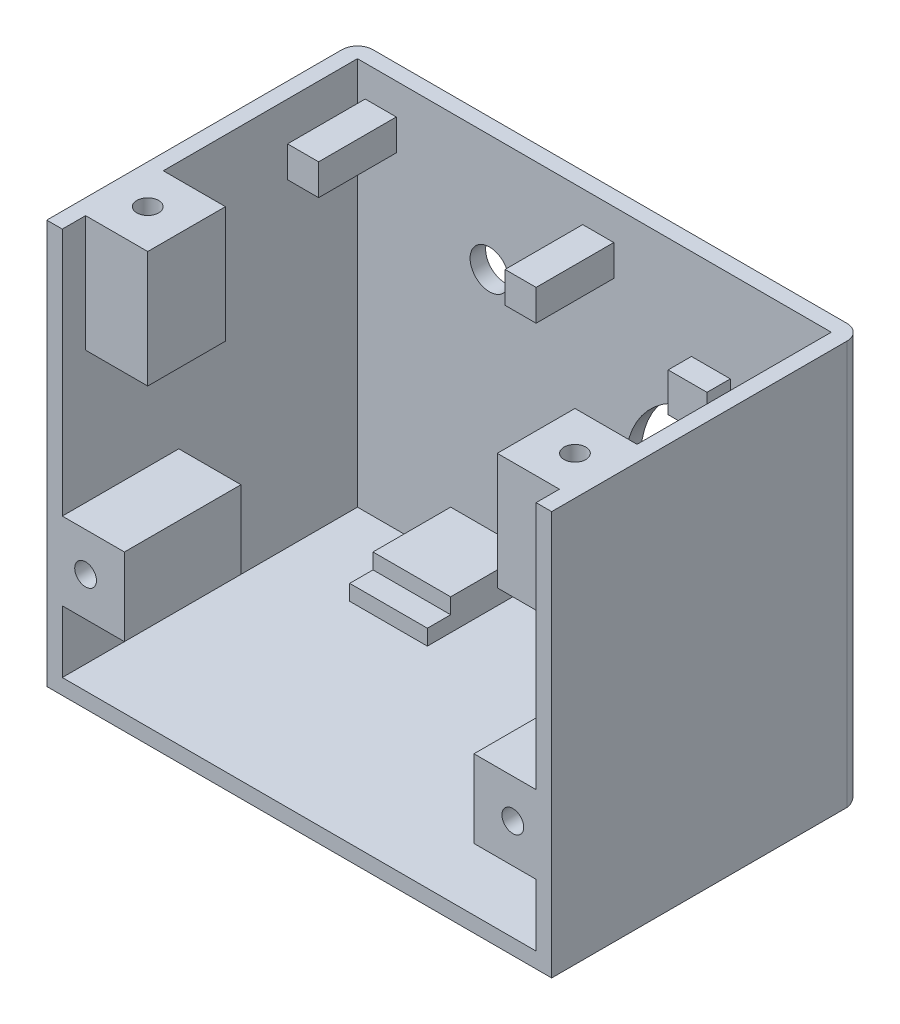
from build123d import *

# Parameters (mm, degrees)
SKETCH1_W           = 65
SKETCH1_H           = 52
BOSS_EXTRUDE1_DEPTH = 40
SHELL1_T            = -2
SKETCH7_W           = 10
SKETCH7_H           = 10
BOSS_EXTRUDE3_DEPTH = 15
SKETCH8_R           = 1.4
CUT_EXTRUDE3_DEPTH  = 10
SKETCH10_W          = 10
SKETCH10_H          = 10
BOSS_EXTRUDE4_DEPTH = 15
SKETCH11_R          = 1.4
CUT_EXTRUDE4_DEPTH  = 10
SKETCH13_R          = 2.5
CUT_EXTRUDE5_DEPTH  = 2
SKETCH16_W          = 10
SKETCH16_H          = 4
BOSS_EXTRUDE5_DEPTH = 13
SKETCH17_W          = 10
SKETCH17_H          = 2
CUT_EXTRUDE6_DEPTH  = 3
SKETCH18_W          = 4
SKETCH18_H          = 4
BOSS_EXTRUDE6_DEPTH = 10
SKETCH20_W          = 4
SKETCH20_H          = 4
BOSS_EXTRUDE7_DEPTH = 10
FILLET1_R           = 2
SKETCH22_W          = 5
SKETCH22_H          = 5
BOSS_EXTRUDE8_DEPTH = 3
SKETCH23_W          = 5
SKETCH23_H          = 5
BOSS_EXTRUDE9_DEPTH = 3
SKETCH24_R          = 11
CUT_EXTRUDE7_DEPTH  = 2


with BuildPart() as part:
    # Sketch1 → Boss-Extrude1 (new body)
    with BuildSketch(Plane.XY):
        with Locations((32.5, 26)):
            Rectangle(SKETCH1_W, SKETCH1_H)
    extrude(amount=BOSS_EXTRUDE1_DEPTH)

    # Shell1
    shell1_openings = [part.faces().sort_by_distance(p)[0] for p in [
        (32.5, 26, 40),
        (32.5, 52, 20),
    ]]
    offset(amount=SHELL1_T, openings=shell1_openings, kind=Kind.INTERSECTION)

    # Sketch7 → Boss-Extrude3 (add)
    with BuildSketch(Plane(origin=(0, 52, 0), x_dir=(1, 0, 0), z_dir=(0, 1, 0))):
        with Locations((5, -32)):
            Rectangle(SKETCH7_W, SKETCH7_H)
    boss_extrude3 = extrude(amount=-BOSS_EXTRUDE3_DEPTH)

    # Sketch8 → Cut-Extrude3 (cut)
    with BuildSketch(Plane(origin=(0, 52, 0), x_dir=(1, 0, 0), z_dir=(0, 1, 0))):
        with Locations((5, -32)):
            Circle(SKETCH8_R)
    cut_extrude3 = extrude(amount=-CUT_EXTRUDE3_DEPTH, mode=Mode.SUBTRACT)

    # Mirror3: Boss-Extrude3, Cut-Extrude3 across plane
    add(boss_extrude3.mirror(Plane(origin=(32.5, 0, 0), x_dir=(0, 0, 1), z_dir=(1, 0, 0))))
    add(cut_extrude3.mirror(Plane(origin=(32.5, 0, 0), x_dir=(0, 0, 1), z_dir=(1, 0, 0))), mode=Mode.SUBTRACT)

    # Sketch10 → Boss-Extrude4 (add)
    with BuildSketch(Plane.XY.offset(40)):
        with Locations((5, 15)):
            Rectangle(SKETCH10_W, SKETCH10_H)
    boss_extrude4 = extrude(amount=-BOSS_EXTRUDE4_DEPTH)

    # Sketch11 → Cut-Extrude4 (cut)
    with BuildSketch(Plane.XY.offset(40)):
        with Locations((5, 15)):
            Circle(SKETCH11_R)
    cut_extrude4 = extrude(amount=-CUT_EXTRUDE4_DEPTH, mode=Mode.SUBTRACT)

    # Mirror4: Boss-Extrude4, Cut-Extrude4 across plane
    add(boss_extrude4.mirror(Plane(origin=(32.5, 0, 0), x_dir=(0, 0, 1), z_dir=(1, 0, 0))))
    add(cut_extrude4.mirror(Plane(origin=(32.5, 0, 0), x_dir=(0, 0, 1), z_dir=(1, 0, 0))), mode=Mode.SUBTRACT)

    # Sketch13 → Cut-Extrude5 (cut)
    with BuildSketch(Plane(origin=(0, 0, 0), x_dir=(-1, 0, 0), z_dir=(0, 0, -1))):
        with Locations((-19, 37)):
            Circle(SKETCH13_R)
    extrude(amount=-CUT_EXTRUDE5_DEPTH, mode=Mode.SUBTRACT)

    # Sketch16 → Boss-Extrude5 (add)
    with BuildSketch(Plane.XY.offset(2)):
        with Locations((19, 6)):
            Rectangle(SKETCH16_W, SKETCH16_H)
    extrude(amount=BOSS_EXTRUDE5_DEPTH)

    # Sketch17 → Cut-Extrude6 (cut)
    with BuildSketch(Plane.XY.offset(15)):
        with Locations((19, 7)):
            Rectangle(SKETCH17_W, SKETCH17_H)
    extrude(amount=-CUT_EXTRUDE6_DEPTH, mode=Mode.SUBTRACT)

    # Sketch18 → Boss-Extrude6 (add)
    with BuildSketch(Plane.XY.offset(2)):
        with Locations((33, 46)):
            Rectangle(SKETCH18_W, SKETCH18_H)
    extrude(amount=BOSS_EXTRUDE6_DEPTH)

    # Sketch20 → Boss-Extrude7 (add)
    with BuildSketch(Plane.XY.offset(2)):
        with Locations((5, 46)):
            Rectangle(SKETCH20_W, SKETCH20_H)
    extrude(amount=BOSS_EXTRUDE7_DEPTH)

    # Fillet1
    fillet1_edges = [part.edges().sort_by_distance(p)[0] for p in [
        (65, 26, 0),
        (32.5, 0, 0),
        (0, 26, 0),
    ]]
    fillet(fillet1_edges, radius=FILLET1_R)

    # Sketch22 → Boss-Extrude8 (add)
    with BuildSketch(Plane.XY.offset(2)):
        with Locations((47.5, 37.8)):
            Rectangle(SKETCH22_W, SKETCH22_H)
    extrude(amount=BOSS_EXTRUDE8_DEPTH)

    # Sketch23 → Boss-Extrude9 (add)
    with BuildSketch(Plane.XY.offset(2)):
        with Locations((47.5, 10.2)):
            Rectangle(SKETCH23_W, SKETCH23_H)
    extrude(amount=BOSS_EXTRUDE9_DEPTH)

    # Sketch24 → Cut-Extrude7 (cut)
    with BuildSketch(Plane.XY.offset(2)):
        with Locations((47.5, 24.03)):
            Circle(SKETCH24_R)
    extrude(amount=-CUT_EXTRUDE7_DEPTH, mode=Mode.SUBTRACT)


solid = part.part
